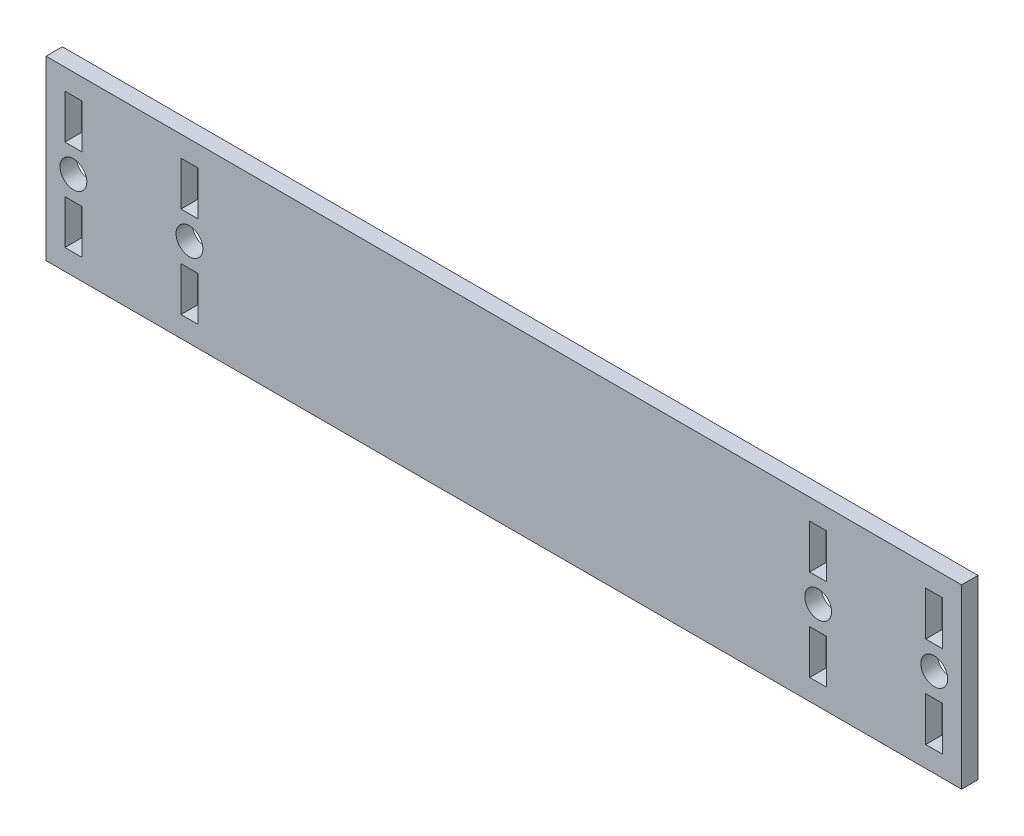
from build123d import *

# Parameters (mm, degrees)
SKETCH1_W           = 184.587896
SKETCH1_H           = 35.687
SKETCH1_R           = 2.7039951
SKETCH1_W_2         = 3.429
SKETCH1_H_2         = 8.89
BOSS_EXTRUDE1_DEPTH = 3.302


with BuildPart() as part:
    # Sketch1 → Boss-Extrude1 (new body)
    with BuildSketch(Plane.XY):
        Rectangle(SKETCH1_W, SKETCH1_H)
        with Locations((-86.769448, 0)):
            Circle(SKETCH1_R, mode=Mode.SUBTRACT)
        with Locations((-63.370448, 0)):
            Circle(SKETCH1_R, mode=Mode.SUBTRACT)
        with Locations((63.370448, 0)):
            Circle(SKETCH1_R, mode=Mode.SUBTRACT)
        with Locations((86.769448, 0)):
            Circle(SKETCH1_R, mode=Mode.SUBTRACT)
        with Locations((-86.769448, 9.2075)):
            Rectangle(SKETCH1_W_2, SKETCH1_H_2, mode=Mode.SUBTRACT)
        with Locations((-86.769448, -9.2075)):
            Rectangle(SKETCH1_W_2, SKETCH1_H_2, mode=Mode.SUBTRACT)
        with Locations((-63.370448, 9.2075)):
            Rectangle(SKETCH1_W_2, SKETCH1_H_2, mode=Mode.SUBTRACT)
        with Locations((-63.370448, -9.2075)):
            Rectangle(SKETCH1_W_2, SKETCH1_H_2, mode=Mode.SUBTRACT)
        with Locations((63.370448, -9.2075)):
            Rectangle(SKETCH1_W_2, SKETCH1_H_2, mode=Mode.SUBTRACT)
        with Locations((63.370448, 9.2075)):
            Rectangle(SKETCH1_W_2, SKETCH1_H_2, mode=Mode.SUBTRACT)
        with Locations((86.769448, -9.2075)):
            Rectangle(SKETCH1_W_2, SKETCH1_H_2, mode=Mode.SUBTRACT)
        with Locations((86.769448, 9.2075)):
            Rectangle(SKETCH1_W_2, SKETCH1_H_2, mode=Mode.SUBTRACT)
    extrude(amount=BOSS_EXTRUDE1_DEPTH)


solid = part.part
